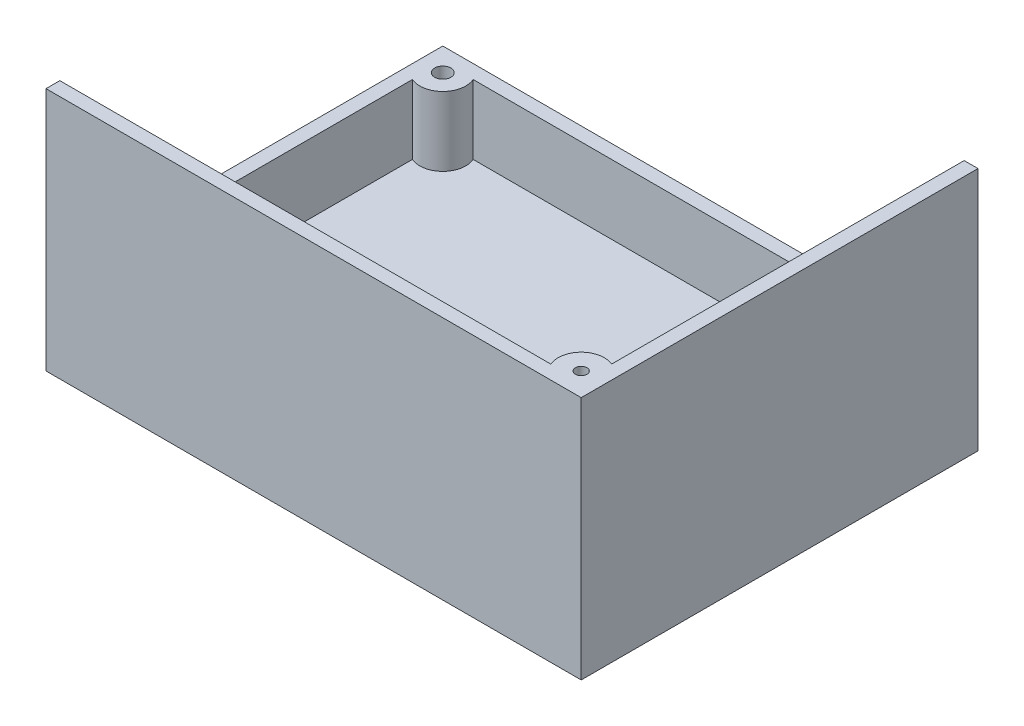
from build123d import *

# Parameters (mm, degrees)
SKETCH1_W           = 110
SKETCH1_H           = 80
BOSS_EXTRUDE1_DEPTH = 3
SKETCH1_3_W         = 116
SKETCH1_3_H         = 86
SKETCH1_3_W_2       = 110
SKETCH1_3_H_2       = 80
BOSS_EXTRUDE2_DEPTH = 53
SKETCH2_R           = 4.5
CUT_EXTRUDE1_DEPTH  = 53
SKETCH3_R           = 5.5
CUT_EXTRUDE2_DEPTH  = 53
SKETCH5_W           = 113
SKETCH5_H           = 35
CUT_EXTRUDE3_DEPTH  = 83
SKETCH6_R           = 5
BOSS_EXTRUDE3_DEPTH = 15
SKETCH8_R           = 1.75
CUT_EXTRUDE4_DEPTH  = 25
SKETCH9_R           = 3
CUT_EXTRUDE5_DEPTH  = 10
SKETCH10_R          = 5
SKETCH10_R_2        = 1.25
BOSS_EXTRUDE4_DEPTH = 50
SKETCH11_W          = 33.464657476
SKETCH11_H          = 24.968484897
CUT_EXTRUDE7_DEPTH  = 35


with BuildPart() as part:
    # Sketch1 → Boss-Extrude1 (new body)
    with BuildSketch(Plane(origin=(0, 0, 0), x_dir=(1, 0, 0), z_dir=(0, 1, 0))):
        with Locations((55, 40)):
            Rectangle(SKETCH1_W, SKETCH1_H)
    extrude(amount=BOSS_EXTRUDE1_DEPTH)

    # Sketch1_3 → Boss-Extrude2 (add)
    with BuildSketch(Plane(origin=(0, 0, 0), x_dir=(1, 0, 0), z_dir=(0, 1, 0))):
        with Locations((55, 40)):
            Rectangle(SKETCH1_3_W, SKETCH1_3_H)
        with Locations((55, 40)):
            Rectangle(SKETCH1_3_W_2, SKETCH1_3_H_2, mode=Mode.SUBTRACT)
    extrude(amount=BOSS_EXTRUDE2_DEPTH)

    # Sketch2 → Cut-Extrude1 (cut)
    with BuildSketch(Plane.ZY.offset(3)):
        with Locations((-7, 18)):
            Circle(SKETCH2_R)
    extrude(amount=-CUT_EXTRUDE1_DEPTH, mode=Mode.SUBTRACT)

    # Sketch3 → Cut-Extrude2 (cut)
    with BuildSketch(Plane(origin=(0, 0, -83), x_dir=(-1, 0, 0), z_dir=(0, 0, -1))):
        with Locations((-93, 18)):
            Circle(SKETCH3_R)
    extrude(amount=-CUT_EXTRUDE2_DEPTH, mode=Mode.SUBTRACT)

    # Sketch5 → Cut-Extrude3 (cut)
    with BuildSketch(Plane(origin=(0, 0, -83), x_dir=(-1, 0, 0), z_dir=(0, 0, -1))):
        with Locations((-53.5, 35.5)):
            Rectangle(SKETCH5_W, SKETCH5_H)
    extrude(amount=-CUT_EXTRUDE3_DEPTH, mode=Mode.SUBTRACT)

    # Sketch6 → Boss-Extrude3 (add)
    with BuildSketch(Plane(origin=(0, 3, 0), x_dir=(1, 0, 0), z_dir=(0, 1, 0))):
        with Locations((2, 78)):
            Circle(SKETCH6_R)
    extrude(amount=BOSS_EXTRUDE3_DEPTH)

    # Sketch8 → Cut-Extrude4 (cut)
    with BuildSketch(Plane(origin=(0, 18, 0), x_dir=(1, 0, 0), z_dir=(0, 1, 0))):
        with Locations((2, 78)):
            Circle(SKETCH8_R)
    extrude(amount=-CUT_EXTRUDE4_DEPTH, mode=Mode.SUBTRACT)

    # Sketch9 → Cut-Extrude5 (cut)
    with BuildSketch(Plane(origin=(0, 0, 0), x_dir=(-1, 0, 0), z_dir=(0, -1, 0))):
        with Locations((-2, 78)):
            Circle(SKETCH9_R)
    extrude(amount=-CUT_EXTRUDE5_DEPTH, mode=Mode.SUBTRACT)

    # Sketch10 → Boss-Extrude4 (add)
    with BuildSketch(Plane(origin=(0, 3, 0), x_dir=(1, 0, 0), z_dir=(0, 1, 0))):
        with Locations((108, 2)):
            Circle(SKETCH10_R)
        with Locations((108, 2)):
            Circle(SKETCH10_R_2, mode=Mode.SUBTRACT)
    extrude(amount=BOSS_EXTRUDE4_DEPTH)

    # Sketch11 → Cut-Extrude7 (cut)
    with BuildSketch(Plane(origin=(0, 3, 0), x_dir=(1, 0, 0), z_dir=(0, 1, 0))):
        with Locations((93.267671262, 12.484242449)):
            Rectangle(SKETCH11_W, SKETCH11_H)
    extrude(amount=CUT_EXTRUDE7_DEPTH, mode=Mode.SUBTRACT)


solid = part.part
